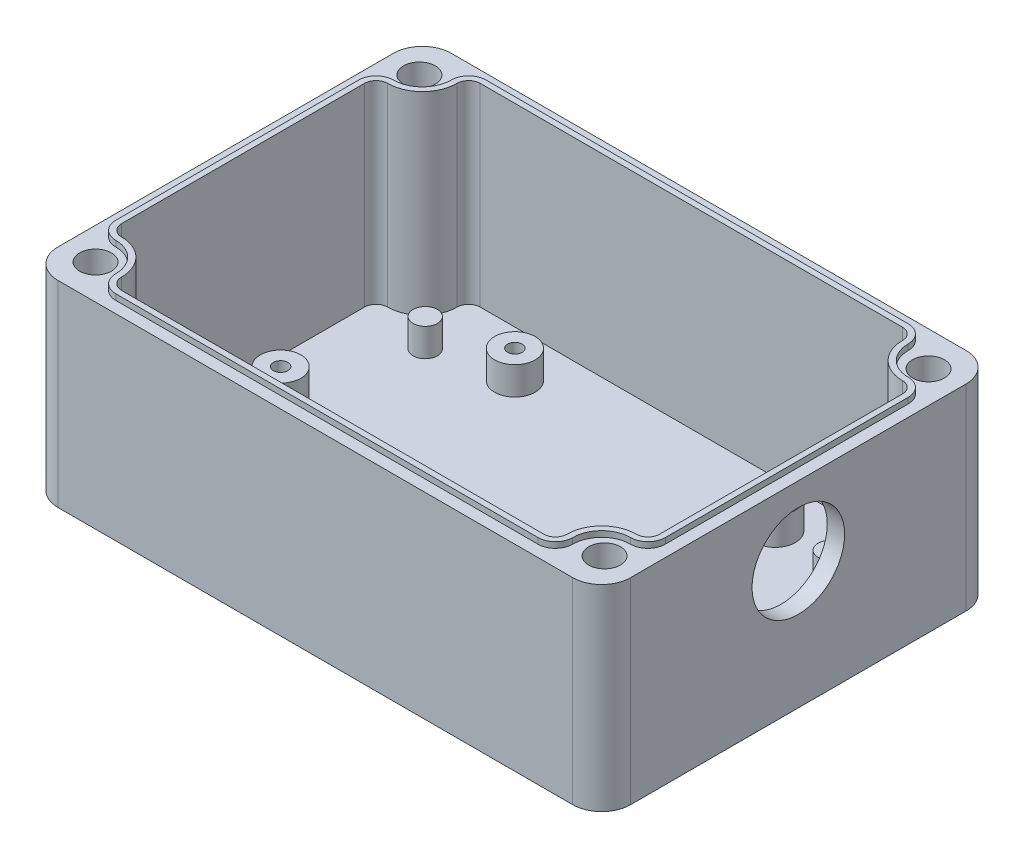
from build123d import *

# Parameters (mm, degrees)
BOSS_EXTRU_1_DEPTH      = 34
ENL_V_MAT_EXTRU_1_DEPTH = 32.5
ENL_V_MAT_EXTRU_2_REACH = 36
ESQUISSE3_R             = 2.75
BOSS_EXTRU_2_DEPTH      = 1
ESQUISSE5_R             = 3.4
ENL_V_MAT_EXTRU_3_DEPTH = 25
ESQUISSE6_R             = 3.5
ESQUISSE6_R_2           = 1.25
ESQUISSE6_R_3           = 2.1
BOSS_EXTRU_3_DEPTH      = 4.85
ENL_V_MAT_EXTRU_4_REACH = 101
ESQUISSE7_R             = 8


with BuildPart() as part:
    # Esquisse1 → Boss.-Extru.1 (new body)
    with BuildSketch(Plane(origin=(0, 0, 0), x_dir=(1, 0, 0), z_dir=(0, 1, 0))):
        with BuildLine():
            Line((-44.5, 34), (44.5, 34))
            ThreePointArc((44.5, 34), (48.035533906, 32.535533906), (49.5, 29))
            Line((49.5, 29), (49.5, -29))
            ThreePointArc((49.5, -29), (48.035533906, -32.535533906), (44.5, -34))
            Line((44.5, -34), (-44.5, -34))
            ThreePointArc((-44.5, -34), (-48.035533906, -32.535533906), (-49.5, -29))
            Line((-49.5, -29), (-49.5, 29))
            ThreePointArc((-49.5, 29), (-48.035533906, 32.535533906), (-44.5, 34))
        make_face()
    extrude(amount=BOSS_EXTRU_1_DEPTH)

    # Esquisse2 → Enlèv. mat.-Extru.1 (cut)
    with BuildSketch(Plane(origin=(0, 34, 0), x_dir=(1, 0, 0), z_dir=(0, 1, 0))):
        with BuildLine():
            Line((-36.5, 31), (36.5, 31))
            ThreePointArc((36.5, 31), (37.914213562, 30.414213562), (38.5, 29))
            ThreePointArc((38.5, 29), (40.257359313, 24.757359313), (44.5, 23))
            ThreePointArc((44.5, 23), (45.914213562, 22.414213562), (46.5, 21))
            Line((46.5, 21), (46.5, -21))
            ThreePointArc((46.5, -21), (45.914213562, -22.414213562), (44.5, -23))
            ThreePointArc((44.5, -23), (40.257359313, -24.757359313), (38.5, -29))
            ThreePointArc((38.5, -29), (37.914213562, -30.414213562), (36.5, -31))
            Line((36.5, -31), (-36.5, -31))
            ThreePointArc((-36.5, -31), (-37.914213562, -30.414213562), (-38.5, -29))
            ThreePointArc((-38.5, -29), (-40.257359313, -24.757359313), (-44.5, -23))
            ThreePointArc((-44.5, -23), (-45.914213562, -22.414213562), (-46.5, -21))
            Line((-46.5, -21), (-46.5, 21))
            ThreePointArc((-46.5, 21), (-45.914213562, 22.414213562), (-44.5, 23))
            ThreePointArc((-44.5, 23), (-40.257359313, 24.757359313), (-38.5, 29))
            ThreePointArc((-38.5, 29), (-37.914213562, 30.414213562), (-36.5, 31))
        make_face()
    extrude(amount=-ENL_V_MAT_EXTRU_1_DEPTH, mode=Mode.SUBTRACT)

    # Esquisse3 → Enlèv. mat.-Extru.2 (cut, up to next)
    with BuildSketch(Plane(origin=(0, 34, 0), x_dir=(1, 0, 0), z_dir=(0, 1, 0)), mode=Mode.PRIVATE) as enl_v_mat_extru_2_sk1:
        with Locations(Location((-44, 28, 0), (0, 0, 270))):  # turned: the seam where the file's is
            Circle(ESQUISSE3_R)
    enl_v_mat_extru_2_tool1 = extrude(enl_v_mat_extru_2_sk1.sketch, amount=-ENL_V_MAT_EXTRU_2_REACH, mode=Mode.PRIVATE) & part.part
    add(enl_v_mat_extru_2_tool1.solids().sort_by_distance((-44, 34, -28))[0], mode=Mode.SUBTRACT)
    # Esquisse3 → Enlèv. mat.-Extru.2 (cut, up to next)
    with BuildSketch(Plane(origin=(0, 34, 0), x_dir=(1, 0, 0), z_dir=(0, 1, 0)), mode=Mode.PRIVATE) as enl_v_mat_extru_2_sk2:
        with Locations(Location((-44, -28, 0), (0, 0, 270))):  # turned: the seam where the file's is
            Circle(ESQUISSE3_R)
    enl_v_mat_extru_2_tool2 = extrude(enl_v_mat_extru_2_sk2.sketch, amount=-ENL_V_MAT_EXTRU_2_REACH, mode=Mode.PRIVATE) & part.part
    add(enl_v_mat_extru_2_tool2.solids().sort_by_distance((-44, 34, 28))[0], mode=Mode.SUBTRACT)
    # Esquisse3 → Enlèv. mat.-Extru.2 (cut, up to next)
    with BuildSketch(Plane(origin=(0, 34, 0), x_dir=(1, 0, 0), z_dir=(0, 1, 0)), mode=Mode.PRIVATE) as enl_v_mat_extru_2_sk3:
        with Locations(Location((44, -28, 0), (0, 0, 270))):  # turned: the seam where the file's is
            Circle(ESQUISSE3_R)
    enl_v_mat_extru_2_tool3 = extrude(enl_v_mat_extru_2_sk3.sketch, amount=-ENL_V_MAT_EXTRU_2_REACH, mode=Mode.PRIVATE) & part.part
    add(enl_v_mat_extru_2_tool3.solids().sort_by_distance((44, 34, 28))[0], mode=Mode.SUBTRACT)
    # Esquisse3 → Enlèv. mat.-Extru.2 (cut, up to next)
    with BuildSketch(Plane(origin=(0, 34, 0), x_dir=(1, 0, 0), z_dir=(0, 1, 0)), mode=Mode.PRIVATE) as enl_v_mat_extru_2_sk4:
        with Locations(Location((44, 28, 0), (0, 0, 270))):  # turned: the seam where the file's is
            Circle(ESQUISSE3_R)
    enl_v_mat_extru_2_tool4 = extrude(enl_v_mat_extru_2_sk4.sketch, amount=-ENL_V_MAT_EXTRU_2_REACH, mode=Mode.PRIVATE) & part.part
    add(enl_v_mat_extru_2_tool4.solids().sort_by_distance((44, 34, -28))[0], mode=Mode.SUBTRACT)

    # Esquisse4 → Boss.-Extru.2 (add)
    with BuildSketch(Plane(origin=(0, 34, 0), x_dir=(1, 0, 0), z_dir=(0, 1, 0))):
        with BuildLine():
            Line((47.5, -21), (47.5, 21))
            ThreePointArc((47.5, 21), (46.621320344, 23.121320344), (44.5, 24))
            ThreePointArc((44.5, 24), (40.964466094, 25.464466094), (39.5, 29))
            ThreePointArc((39.5, 29), (38.621320344, 31.121320344), (36.5, 32))
            Line((36.5, 32), (-36.5, 32))
            ThreePointArc((-36.5, 32), (-38.621320344, 31.121320344), (-39.5, 29))
            ThreePointArc((-39.5, 29), (-40.964466094, 25.464466094), (-44.5, 24))
            ThreePointArc((-44.5, 24), (-46.621320344, 23.121320344), (-47.5, 21))
            Line((-47.5, 21), (-47.5, -21))
            ThreePointArc((-47.5, -21), (-46.621320344, -23.121320344), (-44.5, -24))
            ThreePointArc((-44.5, -24), (-40.964466094, -25.464466094), (-39.5, -29))
            ThreePointArc((-39.5, -29), (-38.621320344, -31.121320344), (-36.5, -32))
            Line((-36.5, -32), (36.5, -32))
            ThreePointArc((36.5, -32), (38.621320344, -31.121320344), (39.5, -29))
            ThreePointArc((39.5, -29), (40.964466094, -25.464466094), (44.5, -24))
            ThreePointArc((44.5, -24), (46.621320344, -23.121320344), (47.5, -21))
        make_face()
        with BuildLine():
            Line((46.5, -21), (46.5, 21))
            ThreePointArc((46.5, 21), (45.914213562, 22.414213562), (44.5, 23))
            ThreePointArc((44.5, 23), (40.257359313, 24.757359313), (38.5, 29))
            ThreePointArc((38.5, 29), (37.914213562, 30.414213562), (36.5, 31))
            Line((36.5, 31), (-36.5, 31))
            ThreePointArc((-36.5, 31), (-37.914213562, 30.414213562), (-38.5, 29))
            ThreePointArc((-38.5, 29), (-40.257359313, 24.757359313), (-44.5, 23))
            ThreePointArc((-44.5, 23), (-45.914213562, 22.414213562), (-46.5, 21))
            Line((-46.5, 21), (-46.5, -21))
            ThreePointArc((-46.5, -21), (-45.914213562, -22.414213562), (-44.5, -23))
            ThreePointArc((-44.5, -23), (-40.257359313, -24.757359313), (-38.5, -29))
            ThreePointArc((-38.5, -29), (-37.914213562, -30.414213562), (-36.5, -31))
            Line((-36.5, -31), (36.5, -31))
            ThreePointArc((36.5, -31), (37.914213562, -30.414213562), (38.5, -29))
            ThreePointArc((38.5, -29), (40.257359313, -24.757359313), (44.5, -23))
            ThreePointArc((44.5, -23), (45.914213562, -22.414213562), (46.5, -21))
        make_face(mode=Mode.SUBTRACT)
    extrude(amount=BOSS_EXTRU_2_DEPTH)

    # Esquisse5 → Enlèv. mat.-Extru.3 (cut)
    with BuildSketch(Plane.XZ):
        with Locations(Location((-44, 28, 0), (0, 0, 270))):  # turned: the seam where the file's is
            Circle(ESQUISSE5_R)
        with Locations(Location((44, 28, 0), (0, 0, 270))):  # turned: the seam where the file's is
            Circle(ESQUISSE5_R)
        with Locations(Location((44, -28, 0), (0, 0, 270))):  # turned: the seam where the file's is
            Circle(ESQUISSE5_R)
        with Locations(Location((-44, -28, 0), (0, 0, 270))):  # turned: the seam where the file's is
            Circle(ESQUISSE5_R)
    extrude(amount=-ENL_V_MAT_EXTRU_3_DEPTH, mode=Mode.SUBTRACT)

    # Esquisse6 → Boss.-Extru.3 (add)
    with BuildSketch(Plane(origin=(0, 1.5, 0), x_dir=(1, 0, 0), z_dir=(0, 1, 0))):
        with Locations(Location((-22.5, 23, 0), (0, 0, 270))):  # turned: the seam where the file's is
            Circle(ESQUISSE6_R)
        with Locations(Location((-22.5, 23, 0), (0, 0, 270))):  # turned: the seam where the file's is
            Circle(ESQUISSE6_R_2, mode=Mode.SUBTRACT)
        with Locations(Location((-40, 0, 0), (0, 0, 270))):  # turned: the seam where the file's is
            Circle(ESQUISSE6_R)
        with Locations(Location((-40, 0, 0), (0, 0, 270))):  # turned: the seam where the file's is
            Circle(ESQUISSE6_R_2, mode=Mode.SUBTRACT)
        with Locations(Location((-35, 20, 0), (0, 0, 270))):  # turned: the seam where the file's is
            Circle(ESQUISSE6_R_3)
        with Locations(Location((35, 20, 0), (0, 0, 90))):  # turned: the seam where the file's is
            Circle(ESQUISSE6_R_3)
        with Locations(Location((40, 0, 0), (0, 0, 90))):  # turned: the seam where the file's is
            Circle(ESQUISSE6_R)
        with Locations(Location((40, 0, 0), (0, 0, 90))):  # turned: the seam where the file's is
            Circle(ESQUISSE6_R_2, mode=Mode.SUBTRACT)
        with Locations(Location((22.5, 23, 0), (0, 0, 90))):  # turned: the seam where the file's is
            Circle(ESQUISSE6_R)
        with Locations(Location((22.5, 23, 0), (0, 0, 90))):  # turned: the seam where the file's is
            Circle(ESQUISSE6_R_2, mode=Mode.SUBTRACT)
        with Locations(Location((22.5, -23, 0), (0, 0, 270))):  # turned: the seam where the file's is
            Circle(ESQUISSE6_R)
        with Locations(Location((22.5, -23, 0), (0, 0, 270))):  # turned: the seam where the file's is
            Circle(ESQUISSE6_R_2, mode=Mode.SUBTRACT)
        with Locations(Location((35, -20, 0), (0, 0, 270))):  # turned: the seam where the file's is
            Circle(ESQUISSE6_R_3)
        with Locations(Location((-35, -20, 0), (0, 0, 90))):  # turned: the seam where the file's is
            Circle(ESQUISSE6_R_3)
        with Locations(Location((-22.5, -23, 0), (0, 0, 90))):  # turned: the seam where the file's is
            Circle(ESQUISSE6_R)
        with Locations(Location((-22.5, -23, 0), (0, 0, 90))):  # turned: the seam where the file's is
            Circle(ESQUISSE6_R_2, mode=Mode.SUBTRACT)
    extrude(amount=BOSS_EXTRU_3_DEPTH)

    # Esquisse7 → Enlèv. mat.-Extru.4 (cut, up to next)
    with BuildSketch(Plane(origin=(49.5, 0, 0), x_dir=(0, 0, -1), z_dir=(1, 0, 0)), mode=Mode.PRIVATE) as enl_v_mat_extru_4_sk1:
        with Locations((0, 22)):
            Circle(ESQUISSE7_R)
    enl_v_mat_extru_4_tool1 = extrude(enl_v_mat_extru_4_sk1.sketch, amount=-ENL_V_MAT_EXTRU_4_REACH, mode=Mode.PRIVATE) & part.part
    add(enl_v_mat_extru_4_tool1.solids().sort_by_distance((49.5, 22, 0))[0], mode=Mode.SUBTRACT)


solid = part.part
